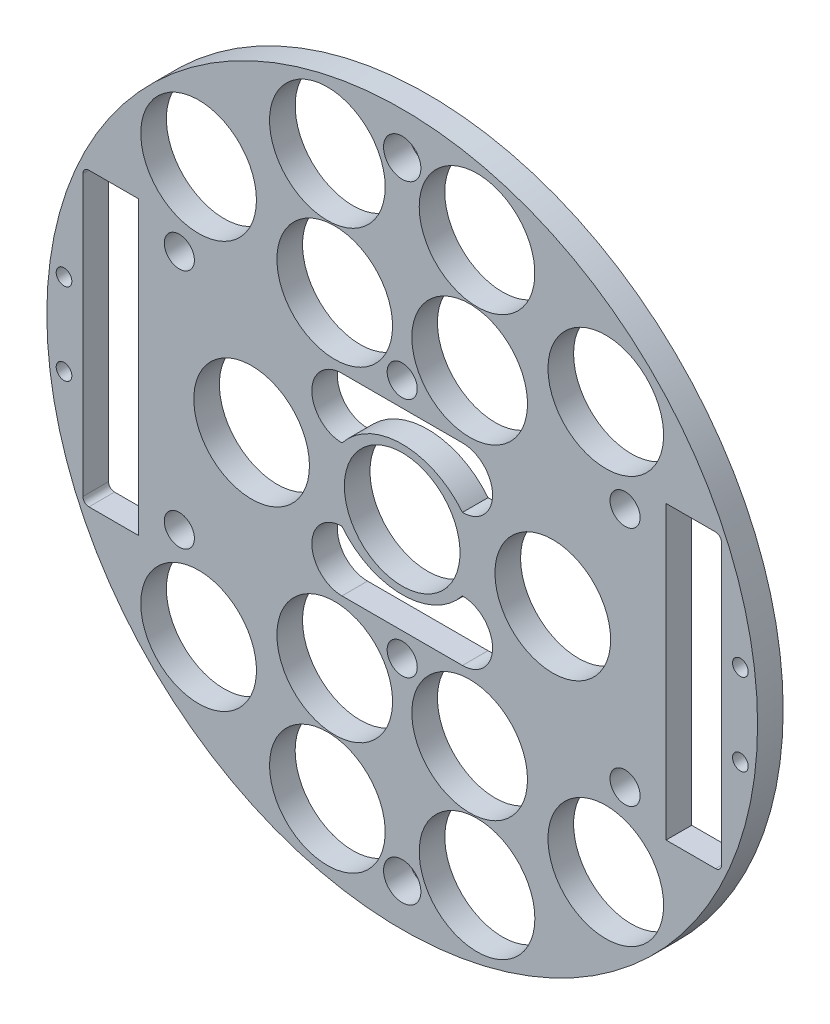
from build123d import *

# Parameters (mm, degrees)
SKETCH1_R                = 1.651
BOSS_EXTRUDE2_DEPTH      = 5.3975
BOSS_EXTRUDE3_DEPTH      = 5.3975
FILLET1_R                = 1.27
SKETCH5_W                = 36.105919561
SKETCH5_H                = 30.801250688
SKETCH5_W_2              = 35.958513686
SKETCH5_H_2              = 33.469345806
BOSS_EXTRUDE4_DEPTH      = 5.3975
SKETCH7_R                = 3.175
CUT_EXTRUDE4_DEPTH       = 234.082045613
CUT_EXTRUDE4_DEPTH_BACK  = 234.082045613
SKETCH8_R                = 4.445
BOSS_EXTRUDE5_DEPTH      = 5.3975
SKETCH12_R               = 12.192
CUT_EXTRUDE8_DEPTH       = 154.925374637
CUT_EXTRUDE8_DEPTH_BACK  = 154.925374637
SKETCH14_R               = 12.192
CUT_EXTRUDE10_DEPTH      = 38.862
SKETCH15_R               = 3.937
CUT_EXTRUDE11_DEPTH      = 21.59
SKETCH16_R               = 1.651
CUT_EXTRUDE12_DEPTH      = 150.876
SKETCH17_R               = 3.175
CUT_EXTRUDE13_DEPTH      = 103.378
CUT_EXTRUDE13_DEPTH_BACK = 48.768


with BuildPart() as part:
    # Sketch1 → Boss-Extrude2 (new body)
    with BuildSketch(Plane.XY):
        with BuildLine():
            Line((-68.336857873, 30.734), (-55.636857873, 30.734))
            Line((-55.636857873, 30.734), (-55.636857873, -30.734))
            Line((-55.636857873, -30.734), (-68.336857873, -30.734))
            ThreePointArc((-68.336857873, -30.734), (0, -74.93), (68.336857873, -30.734))
            Line((68.336857873, -30.734), (55.636857873, -30.734))
            Line((55.636857873, -30.734), (55.636857873, 30.734))
            Line((55.636857873, 30.734), (68.336857873, 30.734))
            ThreePointArc((68.336857873, 30.734), (0, 74.93), (-68.336857873, 30.734))
        make_face()
        with Locations((-45.466, 11.049)):
            Circle(SKETCH1_R, mode=Mode.SUBTRACT)
        with Locations((-20.067270032, 10.795)):
            Circle(SKETCH1_R, mode=Mode.SUBTRACT)
        with Locations(Location((-20.067270032, -10.795, 0), (0, 0, 180))):
            Circle(SKETCH1_R, mode=Mode.SUBTRACT)
        with Locations(Location((-45.466, -11.049, 0), (0, 0, 180))):
            Circle(SKETCH1_R, mode=Mode.SUBTRACT)
        with Locations((45.466, -11.049)):
            Circle(SKETCH1_R, mode=Mode.SUBTRACT)
        with Locations((20.067270032, -10.795)):
            Circle(SKETCH1_R, mode=Mode.SUBTRACT)
        with Locations(Location((20.067270032, 10.795, 0), (0, 0, 180))):
            Circle(SKETCH1_R, mode=Mode.SUBTRACT)
        with Locations(Location((45.466, 11.049, 0), (0, 0, 180))):
            Circle(SKETCH1_R, mode=Mode.SUBTRACT)
    extrude(amount=BOSS_EXTRUDE2_DEPTH)

    # Sketch4 → Boss-Extrude3 (add)
    with BuildSketch(Plane(origin=(0, 0, 0), x_dir=(-1, 0, 0), z_dir=(0, 0, -1))):
        with BuildLine():
            Line((-68.336857873, -30.734), (-67.320857873, -30.734))
            Line((-67.320857873, -30.734), (-67.320857873, 30.734))
            Line((-67.320857873, 30.734), (-68.336857873, 30.734))
            ThreePointArc((-68.336857873, 30.734), (-74.93, 0), (-68.336857873, -30.734))
        make_face()
        with BuildLine():
            Line((67.320857873, 30.734), (68.336857873, 30.734))
            ThreePointArc((68.336857873, 30.734), (74.93, 0), (68.336857873, -30.734))
            Line((68.336857873, -30.734), (67.320857873, -30.734))
            Line((67.320857873, -30.734), (67.320857873, 30.734))
        make_face()
    extrude(amount=-BOSS_EXTRUDE3_DEPTH)

    # Fillet1
    fillet1_edges = [part.edges().sort_by_distance(p)[0] for p in [
        (67.320857873, -30.734, 2.69875),
        (67.320857873, 30.734, 2.69875),
        (-67.320857873, 30.734, 2.69875),
        (-67.320857873, -30.734, 2.69875),
    ]]
    fillet(fillet1_edges, radius=FILLET1_R)

    # Sketch5 → Boss-Extrude4 (add)
    with BuildSketch(Plane(origin=(0, 0, 0), x_dir=(-1, 0, 0), z_dir=(0, 0, -1))):
        with Locations((34.78484389, -0.38515144)):
            Rectangle(SKETCH5_W, SKETCH5_H)
        with Locations((-32.830563904, 0.948896119)):
            Rectangle(SKETCH5_W_2, SKETCH5_H_2)
    extrude(amount=-BOSS_EXTRUDE4_DEPTH)

    # Sketch7 → Cut-Extrude4 (cut, two sides)
    with BuildSketch(Plane(origin=(30.087765895, -133.08292226, 0), x_dir=(-0.008405041193852665, -0.9999646770174084, 0), z_dir=(0, 0, 1))) as cut_extrude4_sk:
        with Locations(Location((-157.958959999, 14.406563609, 0), (0, 0, 90.481579057))):
            Circle(SKETCH7_R)
        with Locations(Location((-173.198959999, -31.313436391, 0), (0, 0, 90.481579057))):
            Circle(SKETCH7_R)
        with Locations(Location((-157.958959999, -77.033436391, 0), (0, 0, 270.481579057))):
            Circle(SKETCH7_R)
        with Locations(Location((-107.158959999, -77.033436391, 0), (0, 0, 90.481579057))):
            Circle(SKETCH7_R)
        with Locations(Location((-91.918959999, -31.313436391, 0), (0, 0, 270.481579057))):
            Circle(SKETCH7_R)
        with Locations(Location((-107.158959999, 14.406563609, 0), (0, 0, 270.481579057))):
            Circle(SKETCH7_R)
    extrude(amount=CUT_EXTRUDE4_DEPTH, mode=Mode.SUBTRACT)
    extrude(cut_extrude4_sk.sketch, amount=-CUT_EXTRUDE4_DEPTH_BACK, mode=Mode.SUBTRACT)

    # Sketch8 → Boss-Extrude5 (add)
    with BuildSketch(Plane(origin=(0, 0, 0), x_dir=(-1, 0, 0), z_dir=(0, 0, -1))):
        with Locations((-45.821472187, 24.749370396)):
            Circle(SKETCH8_R)
        with Locations((-0.231179981, 40.373110558)):
            Circle(SKETCH8_R)
        with Locations((45.61529788, 25.517927363)):
            Circle(SKETCH8_R)
        with Locations((46.042273972, -25.280278229)):
            Circle(SKETCH8_R)
        with Locations((0.451981767, -40.90401839)):
            Circle(SKETCH8_R)
        with Locations((-45.394496094, -26.048835196)):
            Circle(SKETCH8_R)
    extrude(amount=-BOSS_EXTRUDE5_DEPTH)

    # Sketch12 → Cut-Extrude8 (cut, two sides)
    with BuildSketch(Plane(origin=(54.141453623, -7.598175858, -9.525), x_dir=(-1, 0, 0), z_dir=(0, 0, -1))) as cut_extrude8_sk:
        with Locations((11.215453623, 50.524175858)):
            Circle(SKETCH12_R)
        with Locations((38.363844634, 66.481014229)):
            Circle(SKETCH12_R)
        with Locations((39.917453623, 41.888175858)):
            Circle(SKETCH12_R)
        with Locations((54.141453623, 7.598175858)):
            Circle(SKETCH12_R)
        with Locations(Location((69.919062613, 66.481014229, 0), (0, 0, 180))):
            Circle(SKETCH12_R)
        with Locations(Location((68.365453623, 41.888175858, 0), (0, 0, 180))):
            Circle(SKETCH12_R)
        with Locations(Location((97.067453623, 50.524175858, 0), (0, 0, 180))):
            Circle(SKETCH12_R)
        with Locations((68.365453623, -26.691824142)):
            Circle(SKETCH12_R)
        with Locations((97.067453623, -35.327824142)):
            Circle(SKETCH12_R)
        with Locations((69.919062613, -51.284662512)):
            Circle(SKETCH12_R)
        with Locations(Location((38.363844634, -51.284662512, 0), (0, 0, 180))):
            Circle(SKETCH12_R)
        with Locations(Location((11.215453623, -35.327824142, 0), (0, 0, 180))):
            Circle(SKETCH12_R)
        with Locations(Location((39.917453623, -26.691824142, 0), (0, 0, 180))):
            Circle(SKETCH12_R)
    extrude(amount=CUT_EXTRUDE8_DEPTH, mode=Mode.SUBTRACT)
    extrude(cut_extrude8_sk.sketch, amount=-CUT_EXTRUDE8_DEPTH_BACK, mode=Mode.SUBTRACT)

    # Sketch14 → Cut-Extrude10 (cut)
    with BuildSketch(Plane(origin=(0, 0, 0), x_dir=(-1, 0, 0), z_dir=(0, 0, -1))):
        with Locations((-31.75, 0)):
            Circle(SKETCH14_R)
        with Locations(Location((31.75, 0, 0), (0, 0, 180))):
            Circle(SKETCH14_R)
        with BuildLine():
            Line((-12.7, 20.32), (12.7, 20.32))
            ThreePointArc((12.7, 20.32), (19.05, 13.97), (12.7, 7.62))
            ThreePointArc((12.7, 7.62), (0, 13.754080301), (-12.7, 7.62))
            ThreePointArc((-12.7, 7.62), (-19.05, 13.97), (-12.7, 20.32))
        make_face()
        with BuildLine():
            Line((-12.7, -20.32), (12.7, -20.32))
            ThreePointArc((12.7, -20.32), (19.05, -13.97), (12.7, -7.62))
            ThreePointArc((12.7, -7.62), (0, -13.754080301), (-12.7, -7.62))
            ThreePointArc((-12.7, -7.62), (-19.05, -13.97), (-12.7, -20.32))
        make_face()
    extrude(amount=-CUT_EXTRUDE10_DEPTH, mode=Mode.SUBTRACT)

    # Sketch15 → Cut-Extrude11 (cut)
    with BuildSketch(Plane(origin=(0, 0, 0), x_dir=(-1, 0, 0), z_dir=(0, 0, -1))):
        with Locations((0, -66.04)):
            Circle(SKETCH15_R)
        with Locations(Location((0, 66.04, 0), (0, 0, 180))):
            Circle(SKETCH15_R)
    extrude(amount=-CUT_EXTRUDE11_DEPTH, mode=Mode.SUBTRACT)

    # Sketch16 → Cut-Extrude12 (cut)
    with BuildSketch(Plane(origin=(-30.092005081, 4.08352975, -57.7215), x_dir=(-1, 0, 0), z_dir=(0, 0, -1))):
        with Locations(Location((-101.395980802, -12.71952975, 0), (0, 0, 180))):
            Circle(SKETCH16_R)
        with Locations(Location((-101.395980802, 4.55247025, 0), (0, 0, 180))):
            Circle(SKETCH16_R)
        with Locations(Location((41.211970641, -12.71952975, 0), (0, 0, 180))):
            Circle(SKETCH16_R)
        with Locations(Location((41.211970641, 4.55247025, 0), (0, 0, 180))):
            Circle(SKETCH16_R)
    extrude(amount=-CUT_EXTRUDE12_DEPTH, mode=Mode.SUBTRACT)

    # Sketch17 → Cut-Extrude13 (cut, two sides)
    with BuildSketch(Plane(origin=(-30.092005081, 4.08352975, -46.9265), x_dir=(1, 0, 0), z_dir=(0, 0, 1))) as cut_extrude13_sk:
        with Locations((-16.897994919, 21.31647025)):
            Circle(SKETCH17_R)
        with Locations((77.082005081, 21.31647025)):
            Circle(SKETCH17_R)
        with Locations((30.092005081, 21.31647025)):
            Circle(SKETCH17_R)
        with Locations((77.082005081, -29.48352975)):
            Circle(SKETCH17_R)
        with Locations((30.092005081, -29.48352975)):
            Circle(SKETCH17_R)
        with Locations((-16.897994919, -29.48352975)):
            Circle(SKETCH17_R)
    extrude(amount=CUT_EXTRUDE13_DEPTH, mode=Mode.SUBTRACT)
    extrude(cut_extrude13_sk.sketch, amount=-CUT_EXTRUDE13_DEPTH_BACK, mode=Mode.SUBTRACT)


solid = part.part
